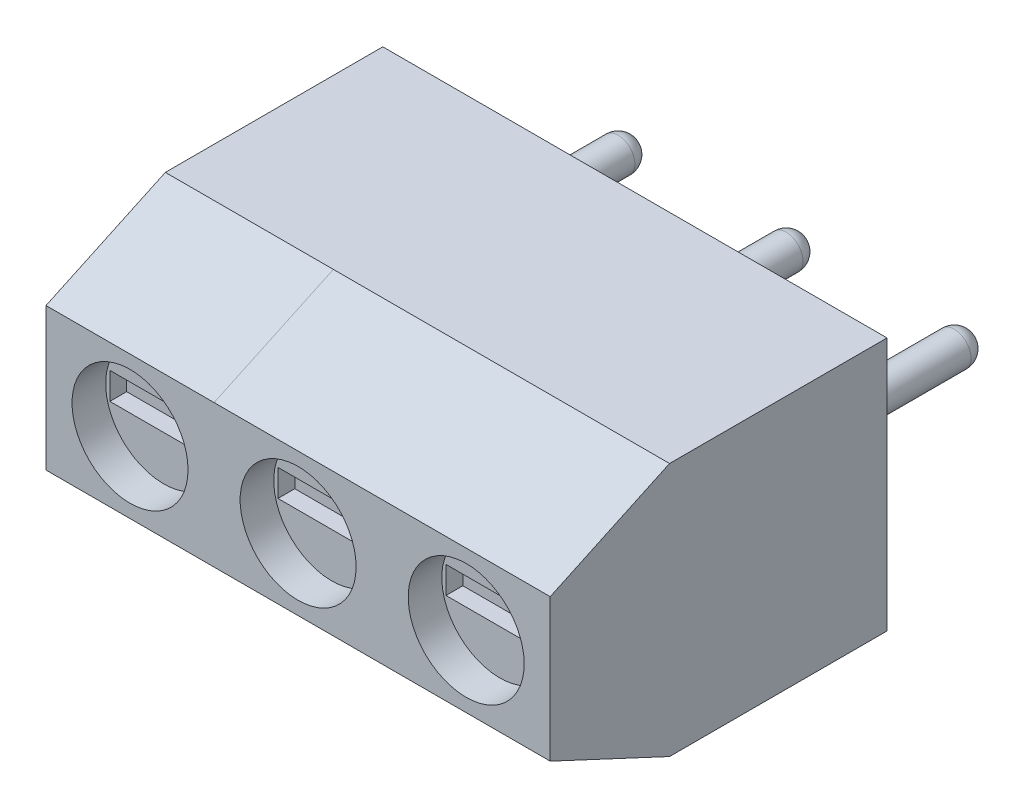
from build123d import *
from OCP.BRepFilletAPI import BRepFilletAPI_MakeChamfer

# Parameters (mm, degrees)
ESQUISSE1_W                      = 5
ESQUISSE1_H                      = 7.55
EXTRUSION1_DEPTH                 = 10.02
CHANFREIN1_SIZE                  = 3.55
CHANFREIN1_SIZE2                 = 1.655392186
ESQUISSE2_R                      = 1.725
ENL_V_MAT_EXTRU_1_DEPTH          = 1
ESQUISSE3_W                      = 4
ESQUISSE3_H                      = 5
ENL_V_MAT_EXTRU_2_DEPTH          = 1.6
ESQUISSE4_R                      = 1.675
ENL_V_MAT_EXTRU_3_DEPTH          = 1.6
ESQUISSE5_R                      = 0.5
EXTRUSION2_DEPTH                 = 5
CONG_1_R                         = 0.5
ESQUISSE6_W                      = 3.2
ESQUISSE6_H                      = 0.8
ENL_V_MAT_EXTRU_4_DEPTH          = 0.5
R_P_TITION_LIN_AIRE5_COUNT       = 3
R_P_TITION_LIN_AIRE5_PITCH       = 5
CONG_1_OF_R_P_TITION_LIN_AIRE5_R = 0.5
CHANFREIN2_SIZE                  = 1.655392186
CHANFREIN2_SIZE2                 = 3.55


with BuildPart() as part:
    # Esquisse1 → Extrusion1 (new body)
    with BuildSketch(Plane.XY):
        with Locations((2.5, 3.775)):
            Rectangle(ESQUISSE1_W, ESQUISSE1_H)
    extrusion1 = extrude(amount=EXTRUSION1_DEPTH)

    # Chanfrein1: one chamfer whose edges measure the first distance from different faces: ONE call of the kernel's chamfer builder (chamfer() names one face for all edges)
    chanfrein1_edges_1 = [part.edges().sort_by_distance(p)[0] for p in [
        (2.5, 7.55, 10.02),
    ]]
    chanfrein1_side_1 = [part.faces().sort_by_distance(p)[0] for p in [
        (2.5, 7.55, 5.01),
    ]]
    chanfrein1_edges_2 = [part.edges().sort_by_distance(p)[0] for p in [
        (2.5, 0, 10.02),
    ]]
    chanfrein1_side_2 = [part.faces().sort_by_distance(p)[0] for p in [
        (2.5, 0, 5.01),
    ]]
    chanfrein1 = BRepFilletAPI_MakeChamfer(part.part.solid().wrapped)
    for e in chanfrein1_edges_1:
        chanfrein1.Add(CHANFREIN1_SIZE, CHANFREIN1_SIZE2, e.wrapped, chanfrein1_side_1[0].wrapped)  # the first distance lies on this face
    for e in chanfrein1_edges_2:
        chanfrein1.Add(CHANFREIN1_SIZE, CHANFREIN1_SIZE2, e.wrapped, chanfrein1_side_2[0].wrapped)  # the first distance lies on this face
    add(Compound.cast(chanfrein1.Shape()), mode=Mode.REPLACE)

    # Esquisse2 → Enlèv. mat.-Extru.1 (cut)
    with BuildSketch(Plane.XY.offset(10.02)):
        with Locations((2.5, 3.775)):
            Circle(ESQUISSE2_R)
    enl_v_mat_extru_1 = extrude(amount=-ENL_V_MAT_EXTRU_1_DEPTH, mode=Mode.SUBTRACT)

    # Esquisse3 → Enlèv. mat.-Extru.2 (cut)
    with BuildSketch(Plane.XZ):
        with Locations((2.5, 3.3)):
            Rectangle(ESQUISSE3_W, ESQUISSE3_H)
    enl_v_mat_extru_2 = extrude(amount=-ENL_V_MAT_EXTRU_2_DEPTH, mode=Mode.SUBTRACT)

    # Esquisse4 → Enlèv. mat.-Extru.3 (cut)
    with BuildSketch(Plane.XZ.offset(-1.6)):
        with Locations(Location((2.5, 3.3, 0), (0, 0, 270))):
            Circle(ESQUISSE4_R)
    enl_v_mat_extru_3 = extrude(amount=-ENL_V_MAT_EXTRU_3_DEPTH, mode=Mode.SUBTRACT)

    # Esquisse5 → Extrusion2 (add)
    with BuildSketch(Plane(origin=(0, 0, 0), x_dir=(-1, 0, 0), z_dir=(0, 0, -1))):
        with Locations((-2.5, 3.775)):
            Circle(ESQUISSE5_R)
    extrusion2 = extrude(amount=EXTRUSION2_DEPTH)

    # Congé1
    cong_1_edges = [part.edges().sort_by_distance(p)[0] for p in [
        (3, 3.775, -5),
    ]]
    fillet(cong_1_edges, radius=CONG_1_R)

    # Esquisse6 → Enlèv. mat.-Extru.4 (cut)
    with BuildSketch(Plane.XY.offset(9.02)):
        with Locations((2.5, 3.775)):
            Rectangle(ESQUISSE6_W, ESQUISSE6_H)
    enl_v_mat_extru_4 = extrude(amount=-ENL_V_MAT_EXTRU_4_DEPTH, mode=Mode.SUBTRACT)

    # Répétition linéaire5: Extrusion1, Enlèv. mat.-Extru.1, Enlèv. mat.-Extru.2, Enlèv. mat.-Extru.3, Extrusion2, Enlèv. mat.-Extru.4 ×3
    with Locations(*[(i * R_P_TITION_LIN_AIRE5_PITCH, 0, 0) for i in range(1, R_P_TITION_LIN_AIRE5_COUNT)]):
        add(extrusion1)
        add(enl_v_mat_extru_1, mode=Mode.SUBTRACT)
        add(enl_v_mat_extru_2, mode=Mode.SUBTRACT)
        add(enl_v_mat_extru_3, mode=Mode.SUBTRACT)
        add(extrusion2)
        add(enl_v_mat_extru_4, mode=Mode.SUBTRACT)

    # Congé1 of Répétition linéaire5
    cong_1_of_r_p_tition_lin_aire5_edges = [part.edges().sort_by_distance(p)[0] for p in [
        (8, 3.775, -5),
        (13, 3.775, -5),
    ]]
    fillet(cong_1_of_r_p_tition_lin_aire5_edges, radius=CONG_1_OF_R_P_TITION_LIN_AIRE5_R)

    # Chanfrein2
    chanfrein2_edges = [part.edges().sort_by_distance(p)[0] for p in [
        (10, 0, 10.02),
        (10, 7.55, 10.02),
    ]]
    chanfrein2_side = [part.faces().sort_by_distance(p)[0] for p in [
        (2.5, 1.823321487, 10.02),
    ]]
    chamfer(chanfrein2_edges, length=CHANFREIN2_SIZE, length2=CHANFREIN2_SIZE2, reference=chanfrein2_side[0])


solid = part.part
